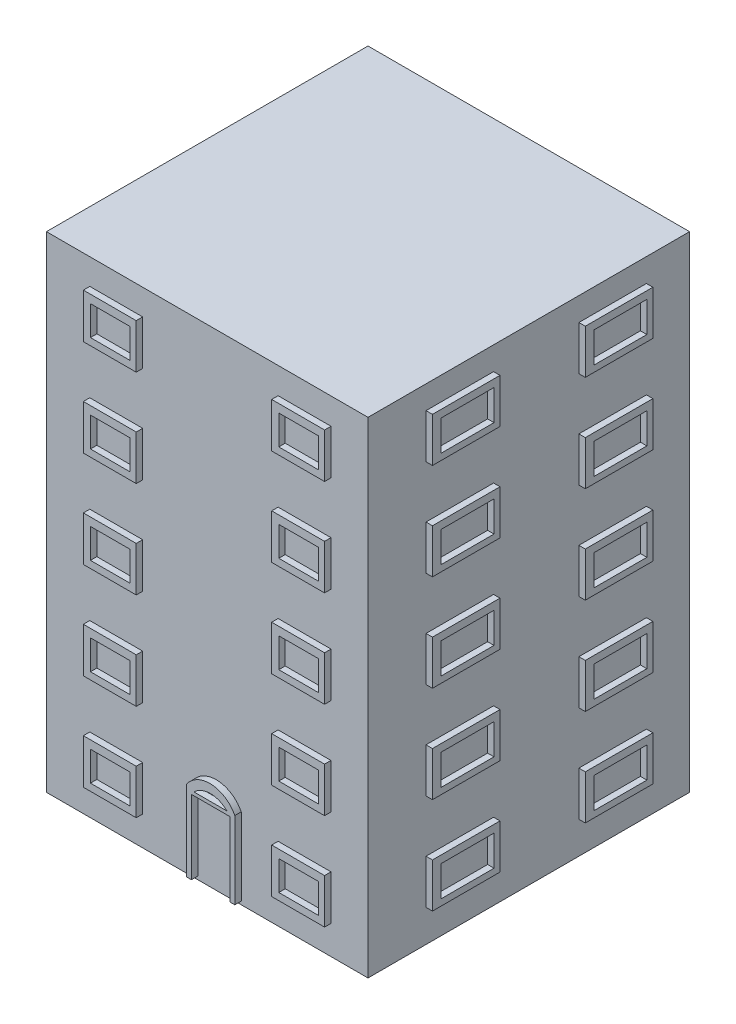
from build123d import *

# Parameters (mm, degrees)
ESBO_O1_W                = 1
ESBO_O1_H                = 1
RESSALTO_EXTRUS_O1_DEPTH = 0.01
ESBO_O2_W                = 1
ESBO_O2_H                = 1
RESSALTO_EXTRUS_O2_DEPTH = 1.5
ESBO_O3_W                = 0.210072298
ESBO_O3_H                = 0.137768345
ESBO_O3_W_2              = 0.164149517
ESBO_O3_H_2              = 0.094776804
ESBO_O3_W_3              = 0.210072299
ESBO_O3_H_3              = 0.137768344
RESSALTO_EXTRUS_O3_DEPTH = 0.02
ESBO_O4_W                = 0.164432046
ESBO_O4_H                = 0.138845427
ESBO_O4_W_2              = 0.123747829
ESBO_O4_H_2              = 0.091430667
ESBO_O4_W_3              = 0.123747828
ESBO_O4_H_3              = 0.091430666
RESSALTO_EXTRUS_O5_DEPTH = 0.02
ESBO_O5_W                = 0.210072298
ESBO_O5_H                = 0.137768344
ESBO_O5_W_2              = 0.164149517
ESBO_O5_H_2              = 0.094776804
ESBO_O5_W_3              = 0.217831917
RESSALTO_EXTRUS_O6_DEPTH = 0.02


with BuildPart() as part:
    # Esboço1 → Ressalto-extrusão1 (new body)
    with BuildSketch(Plane(origin=(0, 0, 0), x_dir=(1, 0, 0), z_dir=(0, 1, 0))):
        with Locations((-0.5, 0)):
            Rectangle(ESBO_O1_W, ESBO_O1_H)
    extrude(amount=RESSALTO_EXTRUS_O1_DEPTH)

    # Esboço2 → Ressalto-extrusão2 (add)
    with BuildSketch(Plane(origin=(0, 0.01, 0), x_dir=(1, 0, 0), z_dir=(0, 1, 0))):
        with Locations((-0.5, 0)):
            Rectangle(ESBO_O2_W, ESBO_O2_H)
    extrude(amount=RESSALTO_EXTRUS_O2_DEPTH)

    # Esboço3 → Ressalto-extrusão3 (add)
    with BuildSketch(Plane(origin=(0, 0, 0), x_dir=(0, 0, -1), z_dir=(1, 0, 0))):
        with Locations((0.260813664, 0.168538388)):
            Rectangle(ESBO_O3_W, ESBO_O3_H)
        with Locations((0.265210526, 0.166726984)):
            Rectangle(ESBO_O3_W_2, ESBO_O3_H_2, mode=Mode.SUBTRACT)
        with Locations((-0.214535979, 0.168884172)):
            Rectangle(ESBO_O3_W_3, ESBO_O3_H_3)
        with Locations((-0.210139117, 0.167072768)):
            Rectangle(ESBO_O3_W_2, ESBO_O3_H_2, mode=Mode.SUBTRACT)
        with Locations((0.260813664, 0.468538389)):
            Rectangle(ESBO_O3_W, ESBO_O3_H)
        with Locations((0.265210526, 0.466726984)):
            Rectangle(ESBO_O3_W_2, ESBO_O3_H_2, mode=Mode.SUBTRACT)
        with Locations((-0.214535979, 0.468884172)):
            Rectangle(ESBO_O3_W_3, ESBO_O3_H_3)
        with Locations((-0.210139117, 0.467072768)):
            Rectangle(ESBO_O3_W_2, ESBO_O3_H_2, mode=Mode.SUBTRACT)
        with Locations((0.260813664, 0.768538389)):
            Rectangle(ESBO_O3_W, ESBO_O3_H)
        with Locations((0.265210526, 0.766726984)):
            Rectangle(ESBO_O3_W_2, ESBO_O3_H_2, mode=Mode.SUBTRACT)
        with Locations((-0.214535979, 0.768884172)):
            Rectangle(ESBO_O3_W_3, ESBO_O3_H_3)
        with Locations((-0.210139117, 0.767072768)):
            Rectangle(ESBO_O3_W_2, ESBO_O3_H_2, mode=Mode.SUBTRACT)
        with Locations((0.260813664, 1.068538389)):
            Rectangle(ESBO_O3_W, ESBO_O3_H)
        with Locations((0.265210526, 1.066726984)):
            Rectangle(ESBO_O3_W_2, ESBO_O3_H_2, mode=Mode.SUBTRACT)
        with Locations((-0.214535979, 1.068884172)):
            Rectangle(ESBO_O3_W_3, ESBO_O3_H_3)
        with Locations((-0.210139117, 1.067072768)):
            Rectangle(ESBO_O3_W_2, ESBO_O3_H_2, mode=Mode.SUBTRACT)
        with Locations((0.260813664, 1.368538388)):
            Rectangle(ESBO_O3_W, ESBO_O3_H)
        with Locations((0.265210526, 1.366726984)):
            Rectangle(ESBO_O3_W_2, ESBO_O3_H_2, mode=Mode.SUBTRACT)
        with Locations((-0.214535979, 1.368884172)):
            Rectangle(ESBO_O3_W_3, ESBO_O3_H_3)
        with Locations((-0.210139117, 1.367072768)):
            Rectangle(ESBO_O3_W_2, ESBO_O3_H_2, mode=Mode.SUBTRACT)
    extrude(amount=RESSALTO_EXTRUS_O3_DEPTH)

    # Esboço4 → Ressalto-extrusão5 (add)
    with BuildSketch(Plane.XY.offset(0.5)):
        with BuildLine():
            Line((-0.544141604, 0.26), (-0.544141604, 0.01))
            Line((-0.544141604, 0.01), (-0.529141604, 0.01))
            Line((-0.529141604, 0.01), (-0.529141604, 0.24))
            Line((-0.529141604, 0.24), (-0.409141604, 0.24))
            Line((-0.409141604, 0.24), (-0.409141604, 0.01))
            Line((-0.409141604, 0.01), (-0.394143151, 0.01))
            Line((-0.394143151, 0.01), (-0.394143151, 0.25049548))
            ThreePointArc((-0.394143151, 0.25049548), (-0.466442379, 0.297858585), (-0.544141604, 0.26))
        make_face()
        with BuildLine():
            Line((-0.418778866, 0.25049548), (-0.521171195, 0.25049548))
            ThreePointArc((-0.521171195, 0.25049548), (-0.469975031, 0.271701626), (-0.418778866, 0.25049548))
        make_face(mode=Mode.SUBTRACT)
        with Locations((-0.197307884, 0.158961603)):
            Rectangle(ESBO_O4_W, ESBO_O4_H)
        with Locations((-0.195612709, 0.157291507)):
            Rectangle(ESBO_O4_W_2, ESBO_O4_H_2, mode=Mode.SUBTRACT)
        with Locations((-0.7829911, 0.160577286)):
            Rectangle(ESBO_O4_W, ESBO_O4_H)
        with Locations((-0.781295924, 0.158907191)):
            Rectangle(ESBO_O4_W_3, ESBO_O4_H_3, mode=Mode.SUBTRACT)
        with Locations((-0.7829911, 0.460577287)):
            Rectangle(ESBO_O4_W, ESBO_O4_H)
        with Locations((-0.781295924, 0.458907191)):
            Rectangle(ESBO_O4_W_3, ESBO_O4_H_3, mode=Mode.SUBTRACT)
        with Locations((-0.197307884, 0.458961603)):
            Rectangle(ESBO_O4_W, ESBO_O4_H)
        with Locations((-0.195612709, 0.457291507)):
            Rectangle(ESBO_O4_W_2, ESBO_O4_H_2, mode=Mode.SUBTRACT)
        with Locations((-0.7829911, 0.760577287)):
            Rectangle(ESBO_O4_W, ESBO_O4_H)
        with Locations((-0.781295924, 0.758907191)):
            Rectangle(ESBO_O4_W_3, ESBO_O4_H_3, mode=Mode.SUBTRACT)
        with Locations((-0.197307884, 0.758961603)):
            Rectangle(ESBO_O4_W, ESBO_O4_H)
        with Locations((-0.195612709, 0.757291507)):
            Rectangle(ESBO_O4_W_2, ESBO_O4_H_2, mode=Mode.SUBTRACT)
        with Locations((-0.7829911, 1.060577287)):
            Rectangle(ESBO_O4_W, ESBO_O4_H)
        with Locations((-0.781295924, 1.058907191)):
            Rectangle(ESBO_O4_W_3, ESBO_O4_H_3, mode=Mode.SUBTRACT)
        with Locations((-0.197307884, 1.058961603)):
            Rectangle(ESBO_O4_W, ESBO_O4_H)
        with Locations((-0.195612709, 1.057291507)):
            Rectangle(ESBO_O4_W_2, ESBO_O4_H_2, mode=Mode.SUBTRACT)
        with Locations((-0.7829911, 1.360577287)):
            Rectangle(ESBO_O4_W, ESBO_O4_H)
        with Locations((-0.781295924, 1.358907191)):
            Rectangle(ESBO_O4_W_3, ESBO_O4_H_3, mode=Mode.SUBTRACT)
        with Locations((-0.197307884, 1.358961602)):
            Rectangle(ESBO_O4_W, ESBO_O4_H)
        with Locations((-0.195612709, 1.357291507)):
            Rectangle(ESBO_O4_W_2, ESBO_O4_H_2, mode=Mode.SUBTRACT)
    extrude(amount=RESSALTO_EXTRUS_O5_DEPTH)

    # Esboço5 → Ressalto-extrusão6 (add)
    with BuildSketch(Plane.ZY.offset(1)):
        with Locations((-0.214963851, 0.158884172)):
            Rectangle(ESBO_O5_W, ESBO_O5_H)
        with Locations((-0.210566988, 0.157072768)):
            Rectangle(ESBO_O5_W_2, ESBO_O5_H_2, mode=Mode.SUBTRACT)
        with Locations((0.268988257, 0.159697318)):
            Rectangle(ESBO_O5_W_3, ESBO_O5_H)
        with Locations((0.269680784, 0.157885913)):
            Rectangle(ESBO_O5_W_2, ESBO_O5_H_2, mode=Mode.SUBTRACT)
        with Locations((-0.214963851, 0.458884172)):
            Rectangle(ESBO_O5_W, ESBO_O5_H)
        with Locations((-0.210566988, 0.457072768)):
            Rectangle(ESBO_O5_W_2, ESBO_O5_H_2, mode=Mode.SUBTRACT)
        with Locations((0.268988257, 0.459697318)):
            Rectangle(ESBO_O5_W_3, ESBO_O5_H)
        with Locations((0.269680784, 0.457885913)):
            Rectangle(ESBO_O5_W_2, ESBO_O5_H_2, mode=Mode.SUBTRACT)
        with Locations((-0.214963851, 0.758884172)):
            Rectangle(ESBO_O5_W, ESBO_O5_H)
        with Locations((-0.210566988, 0.757072768)):
            Rectangle(ESBO_O5_W_2, ESBO_O5_H_2, mode=Mode.SUBTRACT)
        with Locations((0.268988257, 0.759697318)):
            Rectangle(ESBO_O5_W_3, ESBO_O5_H)
        with Locations((0.269680784, 0.757885913)):
            Rectangle(ESBO_O5_W_2, ESBO_O5_H_2, mode=Mode.SUBTRACT)
        with Locations((-0.214963851, 1.058884172)):
            Rectangle(ESBO_O5_W, ESBO_O5_H)
        with Locations((-0.210566988, 1.057072768)):
            Rectangle(ESBO_O5_W_2, ESBO_O5_H_2, mode=Mode.SUBTRACT)
        with Locations((0.268988257, 1.059697318)):
            Rectangle(ESBO_O5_W_3, ESBO_O5_H)
        with Locations((0.269680784, 1.057885913)):
            Rectangle(ESBO_O5_W_2, ESBO_O5_H_2, mode=Mode.SUBTRACT)
        with Locations((-0.214963851, 1.358884172)):
            Rectangle(ESBO_O5_W, ESBO_O5_H)
        with Locations((-0.210566988, 1.357072768)):
            Rectangle(ESBO_O5_W_2, ESBO_O5_H_2, mode=Mode.SUBTRACT)
        with Locations((0.268988257, 1.359697318)):
            Rectangle(ESBO_O5_W_3, ESBO_O5_H)
        with Locations((0.269680784, 1.357885913)):
            Rectangle(ESBO_O5_W_2, ESBO_O5_H_2, mode=Mode.SUBTRACT)
    extrude(amount=RESSALTO_EXTRUS_O6_DEPTH)


solid = part.part
